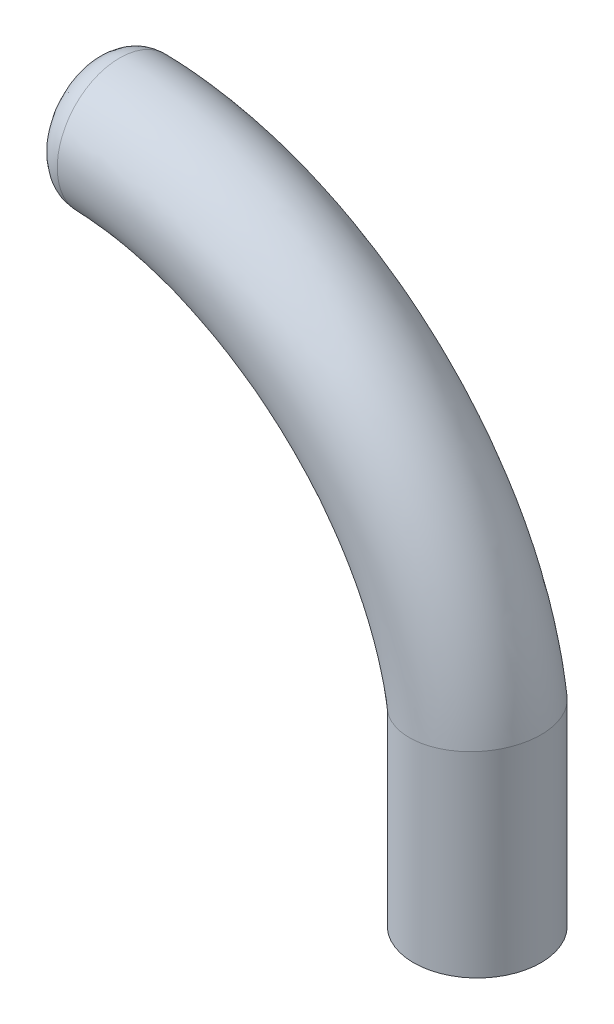
from build123d import *

# Parameters (mm, degrees)
SKETCH1_R = 5
FILLET1_R = 2


with BuildPart() as part:
    # Sweep1: sweep along a path in Sketch2
    with BuildLine(Plane.XY) as sweep1_path:
        Line((0, 0), (0, 15.166536033))
        add(Edge.make_bspline(
            [(0, 15.166536033), (-1.950818089, 29.168228953), (-15.679311829, 40.698163537), (-30, 40)],
            knots=[0, 0, 0, 0, 1, 1, 1, 1], degree=3))
    # Sketch1 → Sweep1 (sweep)
    with BuildSketch(Plane(origin=(0, 0, 0), x_dir=(1, 0, 0), z_dir=(0, 1, 0))):
        Circle(SKETCH1_R)
    sweep(path=sweep1_path.line, transition=Transition.RIGHT)

    # Fillet1
    fillet1_edges = [part.edges().sort_by_distance(p)[0] for p in [
        (-29.756528695, 35.005931346, 0),
    ]]
    fillet(fillet1_edges, radius=FILLET1_R)


solid = part.part
